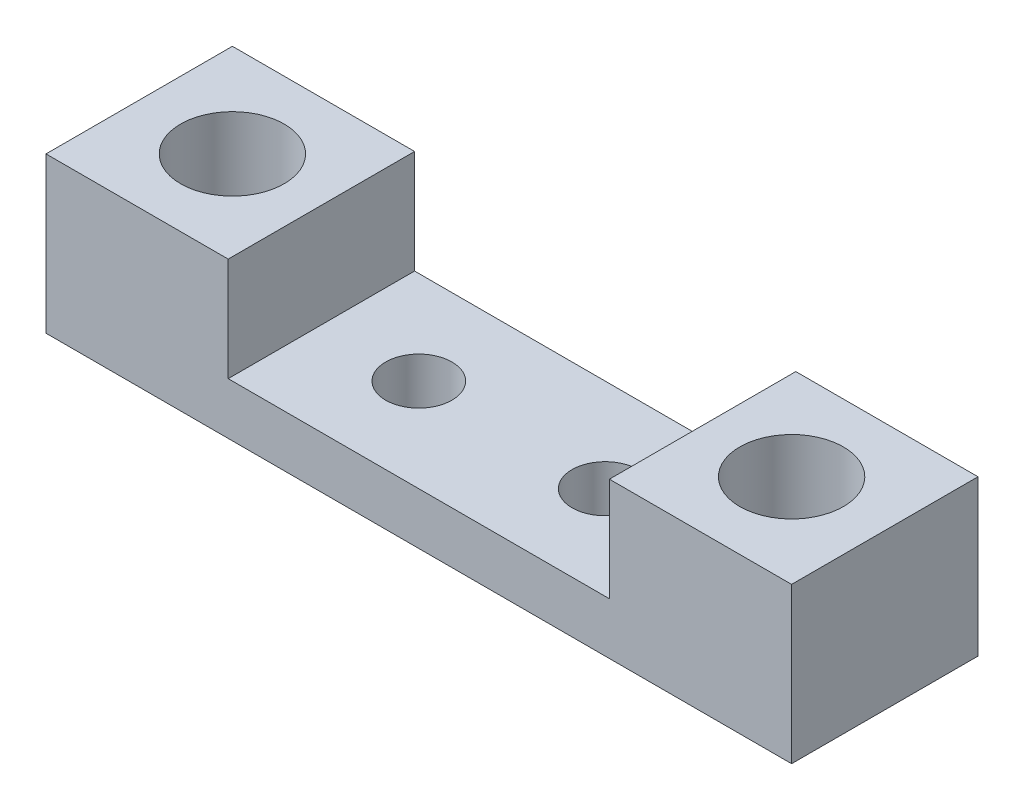
from build123d import *

# Parameters (mm, degrees)
SKETCH1_W           = 36
SKETCH1_H           = 9
SKETCH1_R           = 1.6
SKETCH1_R_2         = 2.5
BOSS_EXTRUDE1_DEPTH = 2.5
SKETCH2_W           = 8.796746506
SKETCH2_H           = 9
SKETCH2_R           = 2.5
BOSS_EXTRUDE2_DEPTH = 5


with BuildPart() as part:
    # Sketch1 → Boss-Extrude1 (new body)
    with BuildSketch(Plane(origin=(0, 0, 0), x_dir=(1, 0, 0), z_dir=(0, 1, 0))):
        with Locations((-8.854143772, 0)):
            Rectangle(SKETCH1_W, SKETCH1_H)
        with Locations((-13.354143772, 0)):
            Circle(SKETCH1_R, mode=Mode.SUBTRACT)
        with Locations((-4.354143772, 0)):
            Circle(SKETCH1_R, mode=Mode.SUBTRACT)
        with Locations((4.645856228, 0)):
            Circle(SKETCH1_R_2, mode=Mode.SUBTRACT)
        with Locations((-22.354143772, 0)):
            Circle(SKETCH1_R_2, mode=Mode.SUBTRACT)
    extrude(amount=BOSS_EXTRUDE1_DEPTH)

    # Sketch2 → Boss-Extrude2 (add)
    with BuildSketch(Plane(origin=(0, 2.5, 0), x_dir=(1, 0, 0), z_dir=(0, 1, 0))):
        with Locations((-22.455770519, 0)):
            Rectangle(SKETCH2_W, SKETCH2_H)
        with Locations((-22.354143772, 0)):
            Circle(SKETCH2_R, mode=Mode.SUBTRACT)
        with Locations((4.747482975, 0)):
            Rectangle(SKETCH2_W, SKETCH2_H)
        with Locations((4.645856228, 0)):
            Circle(SKETCH2_R, mode=Mode.SUBTRACT)
    extrude(amount=BOSS_EXTRUDE2_DEPTH)


solid = part.part
